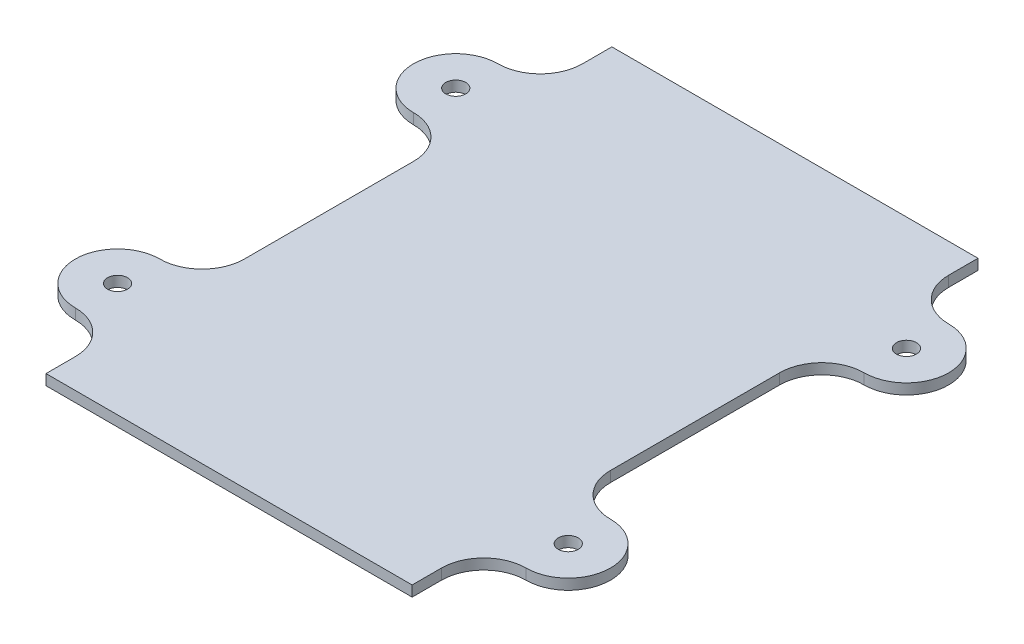
from build123d import *

# Parameters (mm, degrees)
SKETCH1_R               = 1.5
BOSS_EXTRUDE1_DEPTH     = 1.5875
MIRROR2_COPY_1_SKETCH_R = 1.5
MIRROR2_COPY_1_DEPTH    = 1.5875


with BuildPart() as part:
    # Sketch1 → Boss-Extrude1 (new body)
    with BuildSketch(Plane(origin=(0, 0, 0), x_dir=(1, 0, 0), z_dir=(0, 1, 0))):
        with BuildLine():
            Line((-27.5, -42.5), (27.5, -42.5))
            Line((27.5, -42.5), (27.5, 12.7))
            ThreePointArc((27.5, 12.7), (29.359871939, 17.190128061), (33.85, 19.05))
            ThreePointArc((33.85, 19.05), (40.2, 25.4), (33.85, 31.75))
            ThreePointArc((33.85, 31.75), (29.359871939, 33.609871939), (27.5, 38.1))
            Line((27.5, 38.1), (27.5, 42.5))
            Line((27.5, 42.5), (-27.5, 42.5))
            Line((-27.5, 42.5), (-27.5, -42.5))
        make_face()
        with Locations((33.85, 25.4)):
            Circle(SKETCH1_R, mode=Mode.SUBTRACT)
    boss_extrude1 = extrude(amount=BOSS_EXTRUDE1_DEPTH)

    # Mirror1: Boss-Extrude1 across plane
    add(boss_extrude1.mirror(Plane.XY))

    # Mirror2: Boss-Extrude1 across plane
    add(boss_extrude1.mirror(Plane(origin=(0, 0, 0), x_dir=(0, 0, 1), z_dir=(1, 0, 0))))

    # Mirror2 copy 1 sketch → Mirror2 copy 1 (add)
    with BuildSketch(Plane(origin=(0, 0, 0), x_dir=(-1, 0, 0), z_dir=(0, 1, 0))):
        with BuildLine():
            Line((-27.5, -42.5), (27.5, -42.5))
            Line((27.5, -42.5), (27.5, 12.7))
            ThreePointArc((27.5, 12.7), (29.359871939, 17.190128061), (33.85, 19.05))
            ThreePointArc((33.85, 19.05), (40.2, 25.4), (33.85, 31.75))
            ThreePointArc((33.85, 31.75), (29.359871939, 33.609871939), (27.5, 38.1))
            Line((27.5, 38.1), (27.5, 42.5))
            Line((27.5, 42.5), (-27.5, 42.5))
            Line((-27.5, 42.5), (-27.5, -42.5))
        make_face()
        with Locations((33.85, 25.4)):
            Circle(MIRROR2_COPY_1_SKETCH_R, mode=Mode.SUBTRACT)
    extrude(amount=MIRROR2_COPY_1_DEPTH)


solid = part.part
